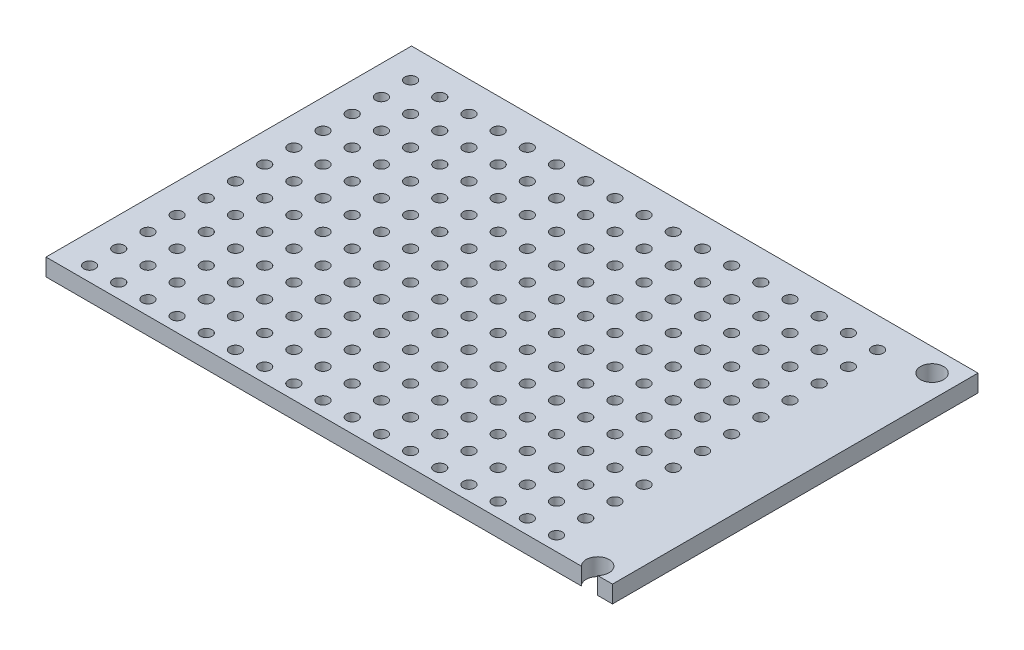
from build123d import *

# Parameters (mm, degrees)
SKETCH1_W            = 45
SKETCH1_H            = 33.1
BOSS_EXTRUDE1_DEPTH  = 0.75
SKETCH2_R            = 0.5
CUT_EXTRUDE1_DEPTH   = 28.971458668
LPATTERN1_COUNT      = 17
LPATTERN1_PITCH      = 2.54
LPATTERN1_COUNT_DIR2 = 12
LPATTERN1_PITCH_DIR2 = 2.54
SKETCH3_W            = 33.1
SKETCH3_H            = 1.5
BOSS_EXTRUDE2_DEPTH  = 4.3
SKETCH4_R            = 1
CUT_EXTRUDE2_DEPTH   = 32.533989599
SKETCH5_W            = 49.3
SKETCH5_H            = 1.5
CUT_EXTRUDE3_DEPTH   = 1.29


with BuildPart() as part:
    # Sketch1 → Boss-Extrude1 (new, symmetric)
    with BuildSketch(Plane(origin=(0, 0, 0), x_dir=(1, 0, 0), z_dir=(0, 1, 0))):
        Rectangle(SKETCH1_W, SKETCH1_H)
    extrude(amount=BOSS_EXTRUDE1_DEPTH, both=True)

    # Sketch2 → Cut-Extrude1 (cut, through all)
    with BuildSketch(Plane(origin=(0, 0.75, 0), x_dir=(1, 0, 0), z_dir=(0, 1, 0))):
        with Locations(Location((-19.96, -14.01, 0), (0, 0, 270))):
            Circle(SKETCH2_R)
    cut_extrude1 = extrude(amount=-CUT_EXTRUDE1_DEPTH, mode=Mode.SUBTRACT)

    # LPattern1: Cut-Extrude1 17 × 12
    with Locations(*[(i * LPATTERN1_PITCH, 0, -j * LPATTERN1_PITCH_DIR2) for i in range(LPATTERN1_COUNT) for j in range(LPATTERN1_COUNT_DIR2) if (i, j) != (0, 0)]):
        add(cut_extrude1, mode=Mode.SUBTRACT)

    # Sketch3 → Boss-Extrude2 (add)
    with BuildSketch(Plane(origin=(22.5, 0, 0), x_dir=(0, 0, -1), z_dir=(1, 0, 0))):
        Rectangle(SKETCH3_W, SKETCH3_H)
    extrude(amount=BOSS_EXTRUDE2_DEPTH)

    # Sketch4 → Cut-Extrude2 (cut, through all)
    with BuildSketch(Plane(origin=(0, 0.75, 0), x_dir=(1, 0, 0), z_dir=(0, 1, 0))):
        with Locations(Location((24.8, -14.55, 0), (0, 0, 270))):
            Circle(SKETCH4_R)
        with Locations(Location((24.8, 14.55, 0), (0, 0, 270))):
            Circle(SKETCH4_R)
    extrude(amount=-CUT_EXTRUDE2_DEPTH, mode=Mode.SUBTRACT)

    # Sketch5 → Cut-Extrude3 (cut)
    with BuildSketch(Plane.XY.offset(16.55)):
        with Locations((2.15, 0)):
            Rectangle(SKETCH5_W, SKETCH5_H)
    extrude(amount=-CUT_EXTRUDE3_DEPTH, mode=Mode.SUBTRACT)


solid = part.part
